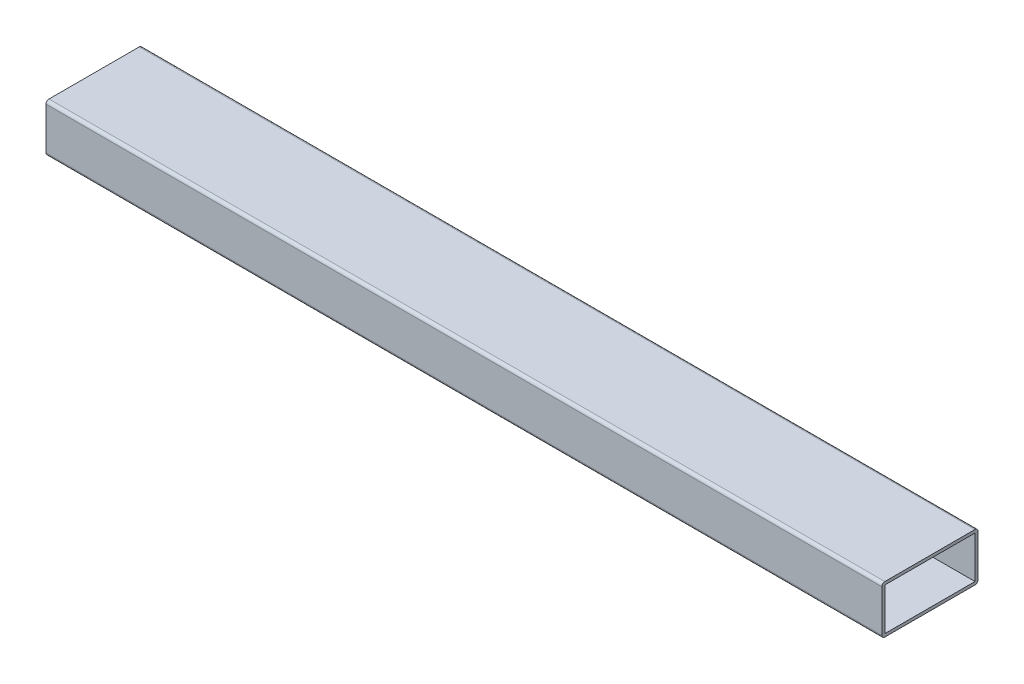
from build123d import *

# Parameters (mm, degrees)
SKETCH1_W           = 50.8
SKETCH1_H           = 25.4
BOSS_EXTRUDE1_DEPTH = 441.450000004
SKETCH2_W           = 47.625
SKETCH2_H           = 22.225
CUT_EXTRUDE1_DEPTH  = 441.45
FILLET1_R           = 1.5875


with BuildPart() as part:
    # Sketch1 → Boss-Extrude1 (new body)
    with BuildSketch(Plane(origin=(0, 0, 0), x_dir=(0, 0, -1), z_dir=(1, 0, 0))):
        with Locations((25.4, 12.7)):
            Rectangle(SKETCH1_W, SKETCH1_H)
    extrude(amount=BOSS_EXTRUDE1_DEPTH)

    # Sketch2 → Cut-Extrude1 (cut)
    with BuildSketch(Plane.ZY):
        with Locations((-25.4, 12.7)):
            Rectangle(SKETCH2_W, SKETCH2_H)
    extrude(amount=-CUT_EXTRUDE1_DEPTH, mode=Mode.SUBTRACT)

    # Fillet1
    fillet1_edges = [part.edges().sort_by_distance(p)[0] for p in [
        (220.725000002, 25.4, 0),
        (220.725000002, 25.4, -50.8),
        (220.725000002, 0, -50.8),
        (220.725000002, 0, 0),
    ]]
    fillet(fillet1_edges, radius=FILLET1_R)


solid = part.part
